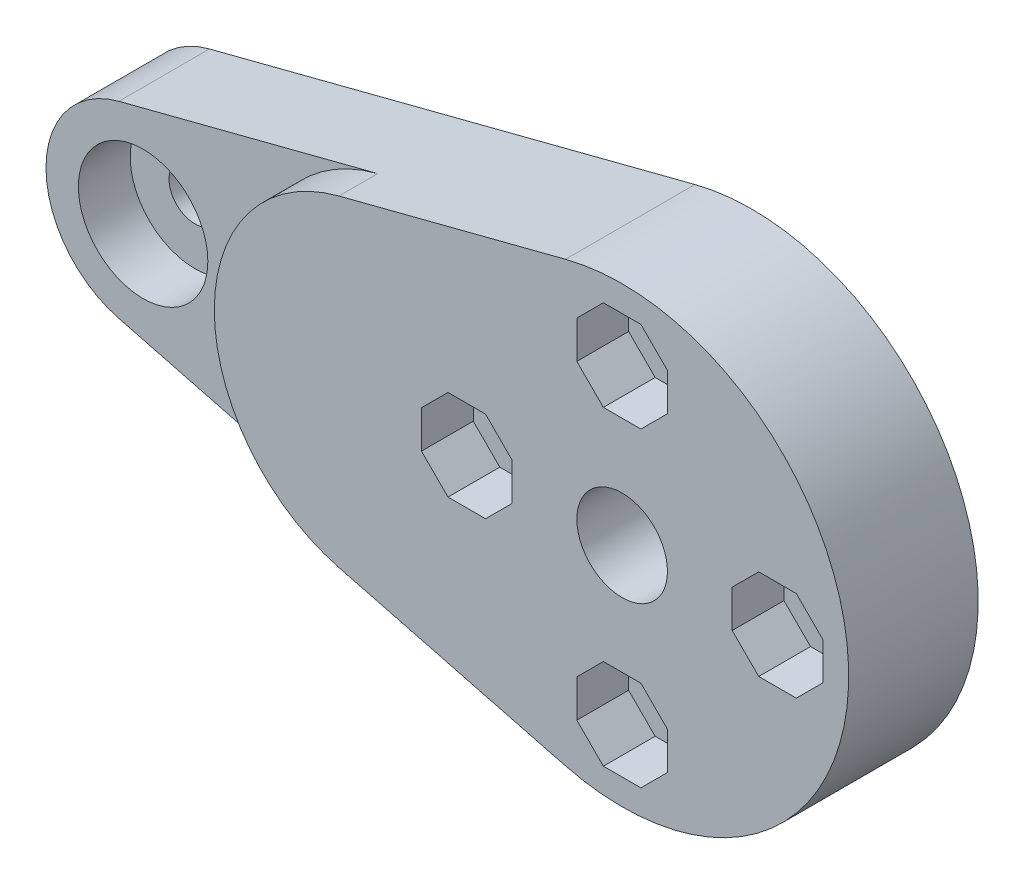
from build123d import *

# Parameters (mm, degrees)
SKETCH1_R           = 2
SKETCH1_R_2         = 3.5
BOSS_EXTRUDE1_DEPTH = 10
SKETCH4_R           = 2
CUT_EXTRUDE2_DEPTH  = 61.930288035
CUT_EXTRUDE3_DEPTH  = 4
CUT_EXTRUDE4_START  = -3
SKETCH5_R           = 2
CUT_EXTRUDE4_DEPTH  = 3
SKETCH6_R           = 5
CUT_EXTRUDE5_DEPTH  = 4
SKETCH7_R           = 6.5
CUT_EXTRUDE6_DEPTH  = 5


with BuildPart() as part:
    # Sketch1 → Boss-Extrude1 (new body)
    with BuildSketch(Plane.XY):
        with BuildLine():
            Line((35.625, 16.94430214), (-1.875, 7.261843774))
            ThreePointArc((-1.875, 7.261843774), (-7.5, 0), (-1.875, -7.261843774))
            Line((-1.875, -7.261843774), (35.625, -16.94430214))
            ThreePointArc((35.625, -16.94430214), (57.5, 0), (35.625, 16.94430214))
        make_face()
        Circle(SKETCH1_R, mode=Mode.SUBTRACT)
        with Locations((40, 0)):
            Circle(SKETCH1_R_2, mode=Mode.SUBTRACT)
    extrude(amount=BOSS_EXTRUDE1_DEPTH)

    # Sketch4 → Cut-Extrude2 (cut, through all)
    with BuildSketch(Plane.XY.offset(10)):
        with Locations((28, 0)):
            Circle(SKETCH4_R)
        with Locations((40, -12)):
            Circle(SKETCH4_R)
        with Locations((52, 0)):
            Circle(SKETCH4_R)
        with Locations((40, 12)):
            Circle(SKETCH4_R)
    extrude(amount=-CUT_EXTRUDE2_DEPTH, mode=Mode.SUBTRACT)

    # Sketch4_3 → Cut-Extrude3 (cut)
    with BuildSketch(Plane.XY.offset(10)):
        Polygon((38.550252532, 8.5), (41.449747468, 8.5), (43.5, 10.550252532), (43.5, 13.449747468), (41.449747468, 15.5), (38.550252532, 15.5), (36.5, 13.449747468), (36.5, 10.550252532), align=None)
        Polygon((50.550252532, 3.5), (48.5, 1.449747468), (48.5, -1.449747468), (50.550252532, -3.5), (53.449747468, -3.5), (55.5, -1.449747468), (55.5, 1.449747468), (53.449747468, 3.5), align=None)
        Polygon((43.5, -10.550252532), (41.449747468, -8.5), (38.550252532, -8.5), (36.5, -10.550252532), (36.5, -13.449747468), (38.550252532, -15.5), (41.449747468, -15.5), (43.5, -13.449747468), align=None)
        Polygon((29.449747468, -3.5), (31.5, -1.449747468), (31.5, 1.449747468), (29.449747468, 3.5), (26.550252532, 3.5), (24.5, 1.449747468), (24.5, -1.449747468), (26.550252532, -3.5), align=None)
    extrude(amount=-CUT_EXTRUDE3_DEPTH, mode=Mode.SUBTRACT)

    # Sketch5 → Cut-Extrude4 (cut)
    with BuildSketch(Plane.XY.offset(10).offset(CUT_EXTRUDE4_START)):
        with BuildLine():
            Line((18.124999859, 12.425821533), (-1.875, 7.261843774))
            ThreePointArc((-1.875, 7.261843774), (-7.5, 0), (-1.875, -7.261843774))
            Line((-1.875, -7.261843774), (18.124999918, -12.425821548))
            ThreePointArc((18.124999918, -12.425821548), (8.5, -3.1e-08), (18.124999859, 12.425821533))
        make_face()
        Circle(SKETCH5_R, mode=Mode.SUBTRACT)
    extrude(amount=CUT_EXTRUDE4_DEPTH, mode=Mode.SUBTRACT)

    # Sketch6 → Cut-Extrude5 (cut)
    with BuildSketch(Plane.XY.offset(7)):
        Circle(SKETCH6_R)
    extrude(amount=-CUT_EXTRUDE5_DEPTH, mode=Mode.SUBTRACT)

    # Sketch7 → Cut-Extrude6 (cut)
    with BuildSketch(Plane(origin=(0, 0, 0), x_dir=(-1, 0, 0), z_dir=(0, 0, -1))):
        with Locations((-40, 0)):
            Circle(SKETCH7_R)
    extrude(amount=-CUT_EXTRUDE6_DEPTH, mode=Mode.SUBTRACT)


solid = part.part
